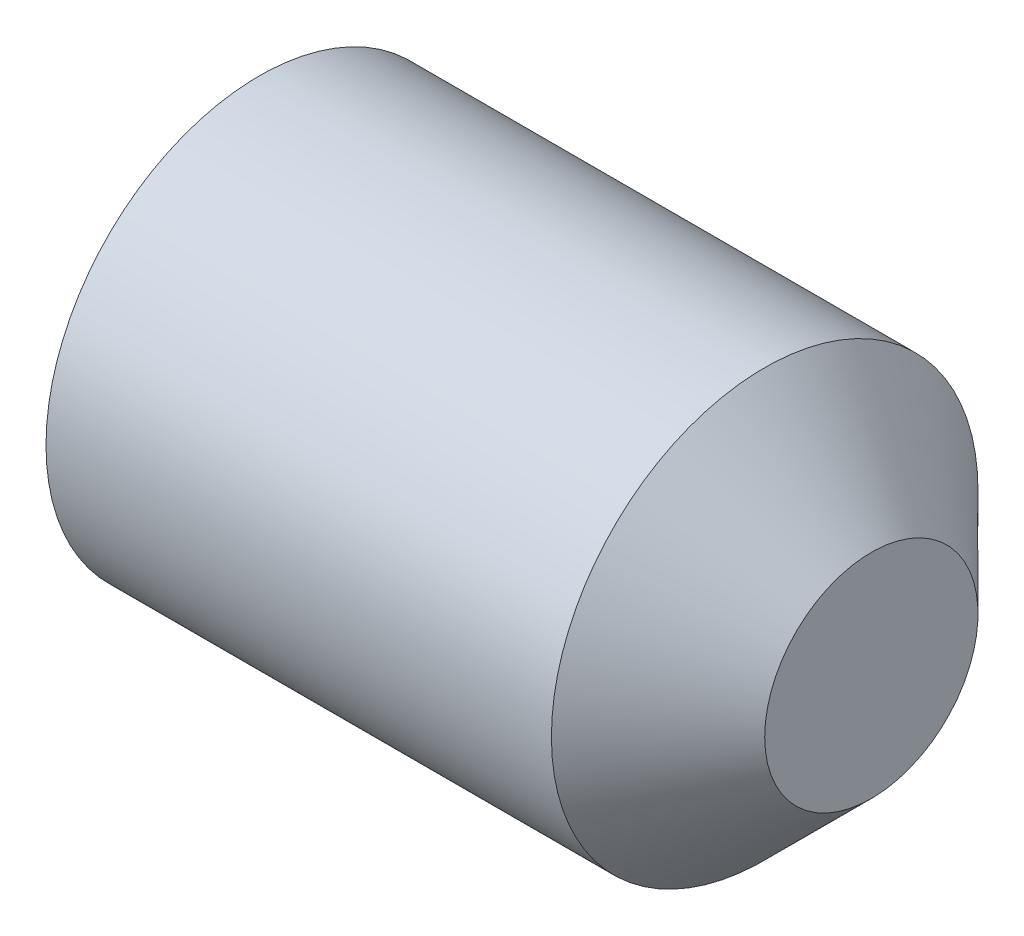
from build123d import *

# Parameters (mm, degrees)
HEX_2_DEPTH = 0.8


with BuildPart() as part:
    # BodySke → BaseBody (revolve)
    with BuildSketch(Plane.XY):
        Polygon((0, 0), (0, 0.774), (0.130481161, 1), (2.5, 1), (3, 0.5), (3, 0), align=None)
    revolve(axis=Axis((-12.7, 0, 0), (1, 0, 0)))

    # Sketch2 → Hex 2 (cut)
    with BuildSketch(Plane.ZY):
        Polygon((0.259807621, 0.45), (-0.259807621, 0.45), (-0.519615242, 0), (-0.259807621, -0.45), (0.259807621, -0.45), (0.519615242, 0), align=None)
    extrude(amount=-HEX_2_DEPTH, mode=Mode.SUBTRACT)


solid = part.part
